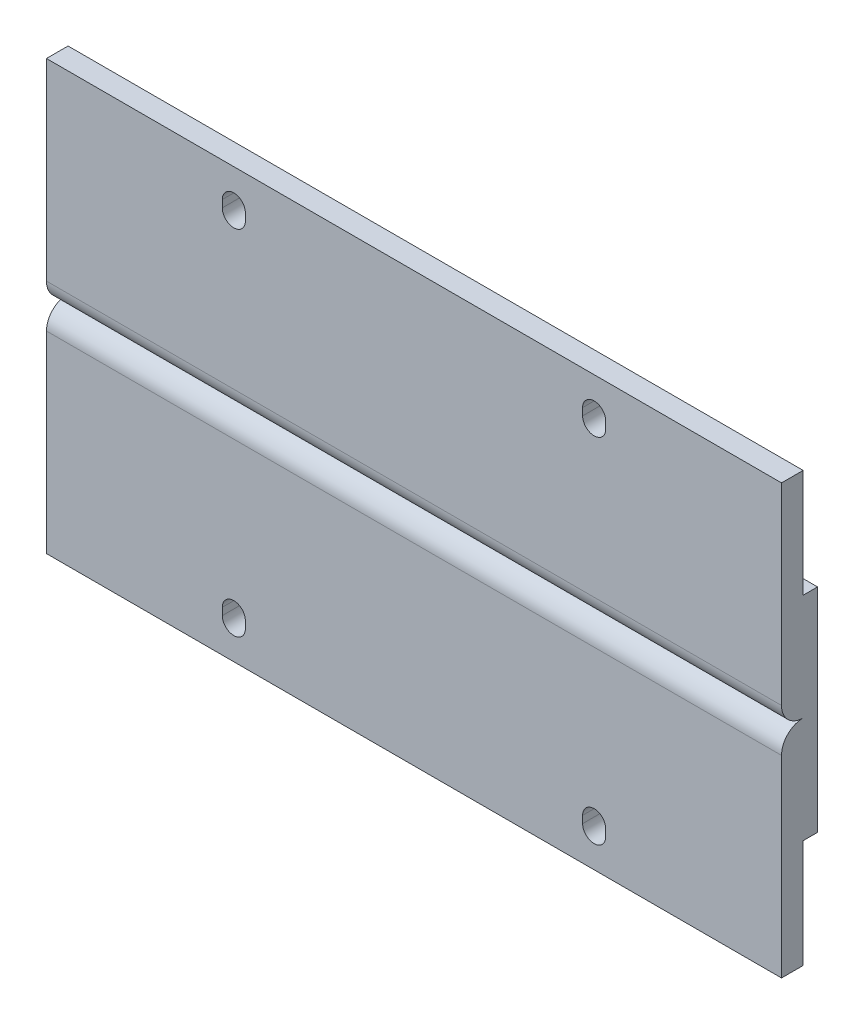
from build123d import *

# Parameters (mm, degrees)
BOSS_EXTRUDE1_DEPTH = 51
CUT_EXTRUDE1_DEPTH  = 6
GREEBLE1_DEPTH      = 52
GREEBLE1_DEPTH_BACK = 52


with BuildPart() as part:
    # Sketch1 → Boss-Extrude1 (new body, symmetric)
    with BuildSketch(Plane(origin=(0, 0, 0), x_dir=(0, 0, -1), z_dir=(1, 0, 0))):
        Polygon((0, 29.75), (0, -29.75), (3, -29.75), (3, -14.75), (5, -14.75), (5, 14.75), (3, 14.75), (3, 29.75), align=None)
    extrude(amount=BOSS_EXTRUDE1_DEPTH, both=True)

    # Sketch3 → Cut-Extrude1 (cut, through all)
    with BuildSketch(Plane.XY):
        with BuildLine():
            Line((23.4, 24), (23.4, 25))
            ThreePointArc((23.4, 25), (25, 26.6), (26.6, 25))
            Line((26.6, 25), (26.6, 24))
            ThreePointArc((26.6, 24), (25, 22.4), (23.4, 24))
        make_face()
        with BuildLine():
            Line((-26.6, 24), (-26.6, 25))
            ThreePointArc((-26.6, 25), (-25, 26.6), (-23.4, 25))
            Line((-23.4, 25), (-23.4, 24))
            ThreePointArc((-23.4, 24), (-25, 22.4), (-26.6, 24))
        make_face()
        with BuildLine():
            Line((26.6, -24), (26.6, -25))
            ThreePointArc((26.6, -25), (25, -26.6), (23.4, -25))
            Line((23.4, -25), (23.4, -24))
            ThreePointArc((23.4, -24), (25, -22.4), (26.6, -24))
        make_face()
        with BuildLine():
            Line((-23.4, -24), (-23.4, -25))
            ThreePointArc((-23.4, -25), (-25, -26.6), (-26.6, -25))
            Line((-26.6, -25), (-26.6, -24))
            ThreePointArc((-26.6, -24), (-25, -22.4), (-23.4, -24))
        make_face()
    extrude(amount=-CUT_EXTRUDE1_DEPTH, mode=Mode.SUBTRACT)

    # Sketch6 → Greeble1 (cut, two sides)
    with BuildSketch(Plane(origin=(0, 0, 0), x_dir=(0, 0, -1), z_dir=(1, 0, 0))) as greeble1_sk:
        with BuildLine():
            ThreePointArc((3, 0), (0.878679656, 0.878679656), (0, 3))
            Line((0, 3), (0, -3))
            ThreePointArc((0, -3), (0.878679656, -0.878679656), (3, 0))
        make_face()
    extrude(amount=GREEBLE1_DEPTH, mode=Mode.SUBTRACT)
    extrude(greeble1_sk.sketch, amount=-GREEBLE1_DEPTH_BACK, mode=Mode.SUBTRACT)


solid = part.part
